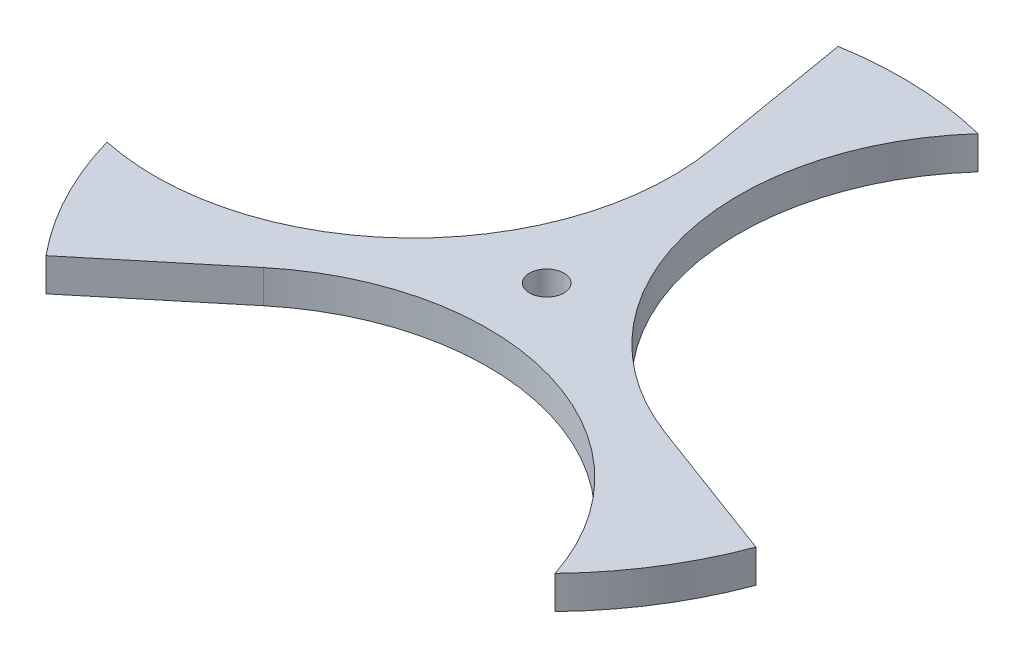
from build123d import *

# Parameters (mm, degrees)
SKETCH1_R           = 3.175
BOSS_EXTRUDE1_DEPTH = 3.048


with BuildPart() as part:
    # Sketch1 → Boss-Extrude1 (new, symmetric)
    with BuildSketch(Plane(origin=(0, 0, 0), x_dir=(1, 0, 0), z_dir=(0, 1, 0))):
        with BuildLine():
            Line((34.700549349, -12.916534941), (61.399556839, -22.854667611))
            ThreePointArc((61.399556839, -22.854667611), (55.420174256, -34.940602415), (47.093148029, -45.546424892))
            ThreePointArc((47.093148029, -45.546424892), (15.086508303, -14.560725649), (-28.536322062, -23.593289791))
            Line((-28.536322062, -23.593289791), (-50.492501165, -41.746242199))
            ThreePointArc((-50.492501165, -41.746242199), (-57.969536443, -30.52497758), (-62.990935022, -18.010650091))
            ThreePointArc((-62.990935022, -18.010650091), (-20.153212462, -5.78493662), (-6.164227287, 36.509824732))
            Line((-6.164227287, 36.509824732), (-10.907055674, 64.600909809))
            ThreePointArc((-10.907055674, 64.600909809), (2.549362187, 65.465579995), (15.897786993, 63.557074983))
            ThreePointArc((15.897786993, 63.557074983), (5.066704158, 20.34566227), (34.700549349, -12.916534941))
        make_face()
        Circle(SKETCH1_R, mode=Mode.SUBTRACT)
    extrude(amount=BOSS_EXTRUDE1_DEPTH, both=True)


solid = part.part
